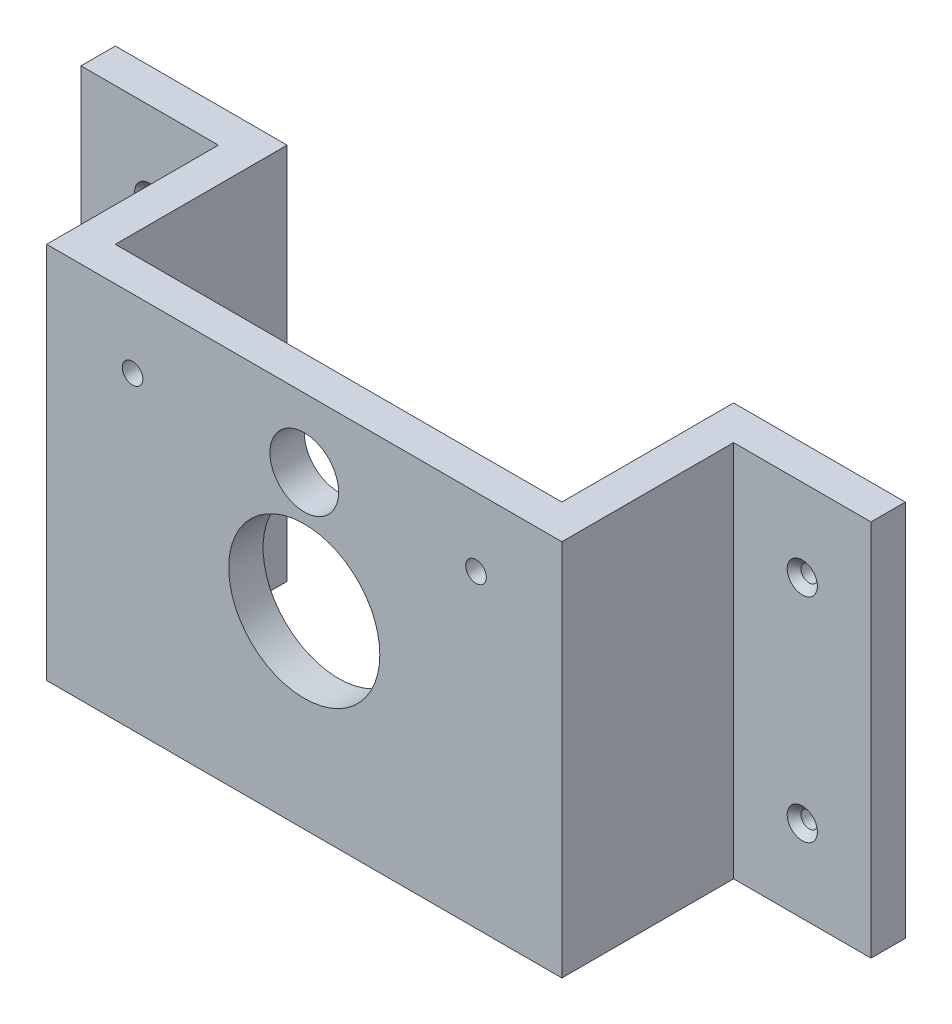
from build123d import *

# Parameters (mm, degrees)
SKETCH1_W                                      = 75
SKETCH1_H                                      = 55
BOSS_EXTRUDE1_DEPTH                            = 5
SKETCH2_W                                      = 5
SKETCH2_H                                      = 55
BOSS_EXTRUDE2_DEPTH                            = 25
CUT_EXTRUDE1_REACH                             = 32
SKETCH3_R                                      = 5
SKETCH3_R_2                                    = 1.5
SKETCH3_R_3                                    = 11
SKETCH4_W                                      = 5
SKETCH4_H                                      = 55
BOSS_EXTRUDE3_DEPTH                            = 20
SKETCH5_W                                      = 5
SKETCH5_H                                      = 55
BOSS_EXTRUDE4_DEPTH                            = 20
M2_D_Z_BA_L_MAKINE_VIDAS_IN_HAV_A1_D           = 2.4
M2_D_Z_BA_L_MAKINE_VIDAS_IN_HAV_A1_CSINK_D     = 4.4
M2_D_Z_BA_L_MAKINE_VIDAS_IN_HAV_A1_CSINK_ANGLE = 90


with BuildPart() as part:
    # Sketch1 → Boss-Extrude1 (new body)
    with BuildSketch(Plane.XY):
        Rectangle(SKETCH1_W, SKETCH1_H)
    extrude(amount=BOSS_EXTRUDE1_DEPTH)

    # Sketch2 → Boss-Extrude2 (add)
    with BuildSketch(Plane(origin=(0, 0, 0), x_dir=(-1, 0, 0), z_dir=(0, 0, -1))):
        with Locations((-35, 0)):
            Rectangle(SKETCH2_W, SKETCH2_H)
        with Locations((35, 0)):
            Rectangle(SKETCH2_W, SKETCH2_H)
    extrude(amount=BOSS_EXTRUDE2_DEPTH)

    # Sketch3 → Cut-Extrude1 (cut, up to next)
    with BuildSketch(Plane.XY.offset(5), mode=Mode.PRIVATE) as cut_extrude1_sk1:
        with Locations((0, 17.5)):
            Circle(SKETCH3_R)
    cut_extrude1_tool1 = extrude(cut_extrude1_sk1.sketch, amount=-CUT_EXTRUDE1_REACH, mode=Mode.PRIVATE) & part.part
    add(cut_extrude1_tool1.solids().sort_by_distance((0, 17.5, 5))[0], mode=Mode.SUBTRACT)
    # Sketch3 → Cut-Extrude1 (cut, up to next)
    with BuildSketch(Plane.XY.offset(5), mode=Mode.PRIVATE) as cut_extrude1_sk2:
        with Locations((-25, 17.5)):
            Circle(SKETCH3_R_2)
    cut_extrude1_tool2 = extrude(cut_extrude1_sk2.sketch, amount=-CUT_EXTRUDE1_REACH, mode=Mode.PRIVATE) & part.part
    add(cut_extrude1_tool2.solids().sort_by_distance((-25, 17.5, 5))[0], mode=Mode.SUBTRACT)
    # Sketch3 → Cut-Extrude1 (cut, up to next)
    with BuildSketch(Plane.XY.offset(5), mode=Mode.PRIVATE) as cut_extrude1_sk3:
        with Locations((25, 17.5)):
            Circle(SKETCH3_R_2)
    cut_extrude1_tool3 = extrude(cut_extrude1_sk3.sketch, amount=-CUT_EXTRUDE1_REACH, mode=Mode.PRIVATE) & part.part
    add(cut_extrude1_tool3.solids().sort_by_distance((25, 17.5, 5))[0], mode=Mode.SUBTRACT)
    # Sketch3 → Cut-Extrude1 (cut, up to next)
    with BuildSketch(Plane.XY.offset(5), mode=Mode.PRIVATE) as cut_extrude1_sk4:
        Circle(SKETCH3_R_3)
    cut_extrude1_tool4 = extrude(cut_extrude1_sk4.sketch, amount=-CUT_EXTRUDE1_REACH, mode=Mode.PRIVATE) & part.part
    add(cut_extrude1_tool4.solids().sort_by_distance((0, 0, 5))[0], mode=Mode.SUBTRACT)

    # Sketch4 → Boss-Extrude3 (add)
    with BuildSketch(Plane(origin=(37.5, 0, 0), x_dir=(0, 0, -1), z_dir=(1, 0, 0))):
        with Locations((22.5, 0)):
            Rectangle(SKETCH4_W, SKETCH4_H)
    extrude(amount=BOSS_EXTRUDE3_DEPTH)

    # Sketch5 → Boss-Extrude4 (add)
    with BuildSketch(Plane.ZY.offset(37.5)):
        with Locations((-22.5, 0)):
            Rectangle(SKETCH5_W, SKETCH5_H)
    extrude(amount=BOSS_EXTRUDE4_DEPTH)

    # M2 Düz Başlı Makine Vidası İçin Havşa1 (through all)
    with Locations(Plane.XY.offset(-20)):
        with Locations((-47.5, 15.5), (-47.5, -15.5), (47.5, 15.5), (47.5, -15.5)):
            CounterSinkHole(M2_D_Z_BA_L_MAKINE_VIDAS_IN_HAV_A1_D / 2, M2_D_Z_BA_L_MAKINE_VIDAS_IN_HAV_A1_CSINK_D / 2, counter_sink_angle=M2_D_Z_BA_L_MAKINE_VIDAS_IN_HAV_A1_CSINK_ANGLE)


solid = part.part
